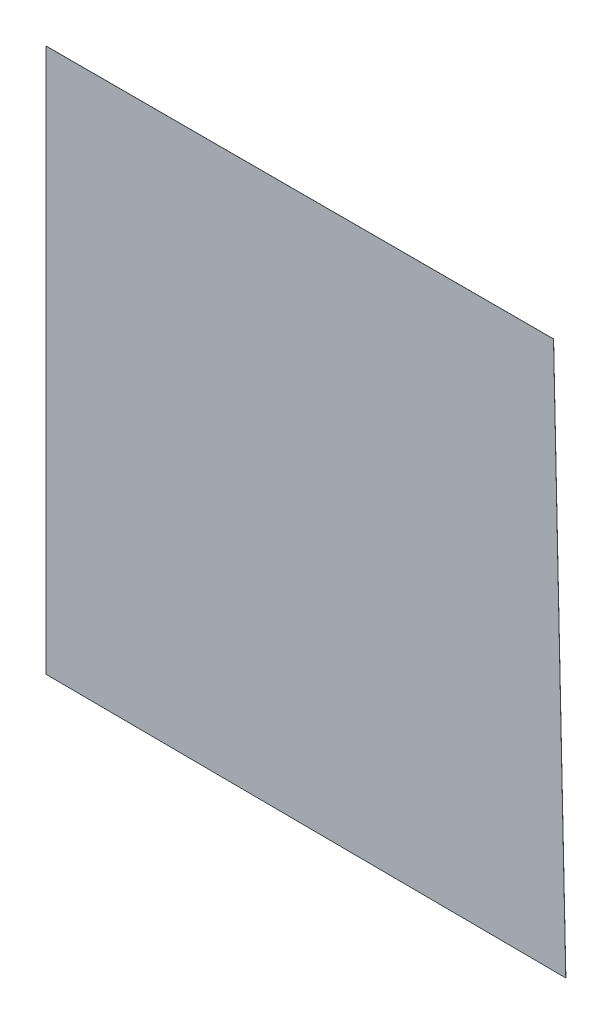
from build123d import *

# Parameters (mm, degrees)
SALIENTE_EXTRUIR1_DEPTH = 2.54


with BuildPart() as part:
    # Croquis2 → Saliente-Extruir1 (new body)
    with BuildSketch(Plane.XY):
        Polygon((-11732.699123433, 15552.259521188), (-11732.699123433, -3406.300478812), (6373.760608427, -3515.401059426), (5945.700876567, 15552.259521188), align=None)
    extrude(amount=SALIENTE_EXTRUIR1_DEPTH)


solid = part.part
